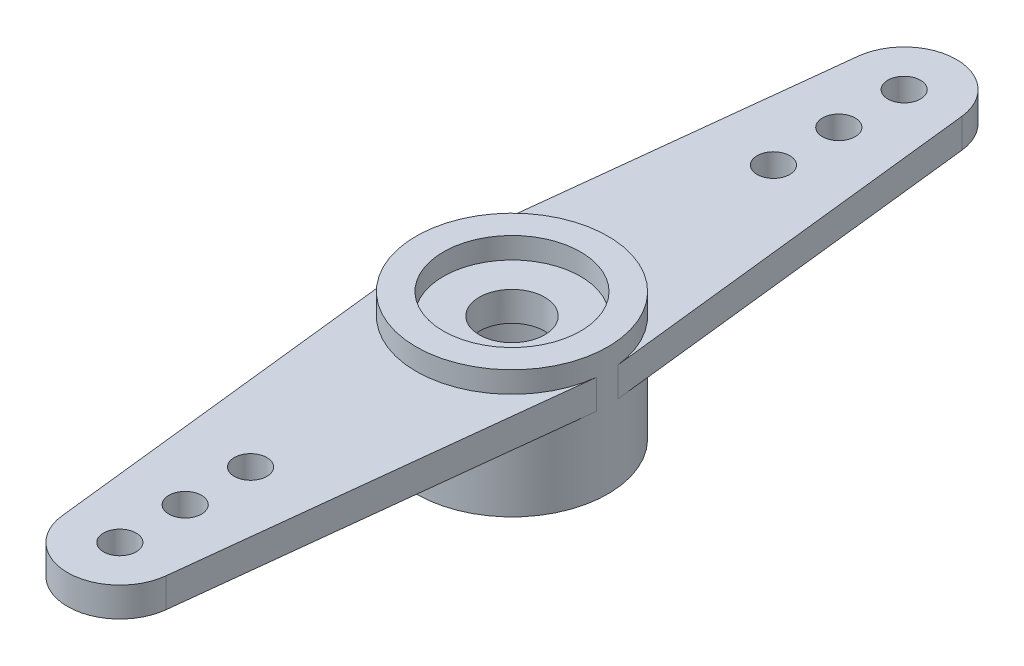
from build123d import *

# Parameters (mm, degrees)
SKETCH1_R           = 2.935
BOSS_EXTRUDE2_DEPTH = 3.25
SKETCH2_R           = 0.5
BOSS_EXTRUDE3_DEPTH = 0.9
SKETCH3_R           = 2.935
BOSS_EXTRUDE4_DEPTH = 0.65
SKETCH4_R           = 2.1
CUT_EXTRUDE1_DEPTH  = 0.65
SKETCH5_R           = 1
CUT_EXTRUDE2_DEPTH  = 5.65
SKETCH6_R           = 2.1
CUT_EXTRUDE3_DEPTH  = 2.35


with BuildPart() as part:
    # Sketch1 → Boss-Extrude2 (new body)
    with BuildSketch(Plane(origin=(0, 0, 0), x_dir=(1, 0, 0), z_dir=(0, 1, 0))):
        Circle(SKETCH1_R)
    extrude(amount=BOSS_EXTRUDE2_DEPTH)

    # Sketch2 → Boss-Extrude3 (add)
    with BuildSketch(Plane(origin=(0, 3.25, 0), x_dir=(1, 0, 0), z_dir=(0, 1, 0))):
        with BuildLine():
            ThreePointArc((-2.916780846, 0.32651875), (-1.956513796, 2.18775656), (0, 2.935))
            ThreePointArc((0, 2.935), (1.956513796, 2.18775656), (2.916780846, 0.32651875))
            Line((2.916780846, 0.32651875), (1.590067923, 12.178))
            ThreePointArc((1.590067923, 12.178), (0, 13.6), (-1.590067923, 12.178))
            Line((-1.590067923, 12.178), (-2.916780846, 0.32651875))
        make_face()
        with BuildLine():
            ThreePointArc((0, 8.5), (0.5, 8), (0, 7.5))
            ThreePointArc((0, 7.5), (-0.5, 8), (0, 8.5))
        make_face(mode=Mode.SUBTRACT)
        with Locations((0, 10)):
            Circle(SKETCH2_R, mode=Mode.SUBTRACT)
        with Locations((0, 12)):
            Circle(SKETCH2_R, mode=Mode.SUBTRACT)
        with BuildLine():
            Line((1.590067923, -12.178), (2.916780846, -0.32651875))
            ThreePointArc((2.916780846, -0.32651875), (0, -2.935), (-2.916780846, -0.32651875))
            Line((-2.916780846, -0.32651875), (-1.590067923, -12.178))
            ThreePointArc((-1.590067923, -12.178), (0, -13.6), (1.590067923, -12.178))
        make_face()
        with Locations((0, -12)):
            Circle(SKETCH2_R, mode=Mode.SUBTRACT)
        with Locations((0, -10)):
            Circle(SKETCH2_R, mode=Mode.SUBTRACT)
        with Locations((0, -8)):
            Circle(SKETCH2_R, mode=Mode.SUBTRACT)
    extrude(amount=-BOSS_EXTRUDE3_DEPTH)

    # Sketch3 → Boss-Extrude4 (add)
    with BuildSketch(Plane(origin=(0, 3.25, 0), x_dir=(1, 0, 0), z_dir=(0, 1, 0))):
        Circle(SKETCH3_R)
    extrude(amount=BOSS_EXTRUDE4_DEPTH)

    # Sketch4 → Cut-Extrude1 (cut)
    with BuildSketch(Plane(origin=(0, 3.9, 0), x_dir=(1, 0, 0), z_dir=(0, 1, 0))):
        Circle(SKETCH4_R)
    extrude(amount=-CUT_EXTRUDE1_DEPTH, mode=Mode.SUBTRACT)

    # Sketch5 → Cut-Extrude2 (cut)
    with BuildSketch(Plane(origin=(0, 3.25, 0), x_dir=(1, 0, 0), z_dir=(0, 1, 0))):
        Circle(SKETCH5_R)
    extrude(amount=-CUT_EXTRUDE2_DEPTH, mode=Mode.SUBTRACT)

    # Sketch6 → Cut-Extrude3 (cut)
    with BuildSketch(Plane.XZ):
        Circle(SKETCH6_R)
    extrude(amount=-CUT_EXTRUDE3_DEPTH, mode=Mode.SUBTRACT)


solid = part.part
